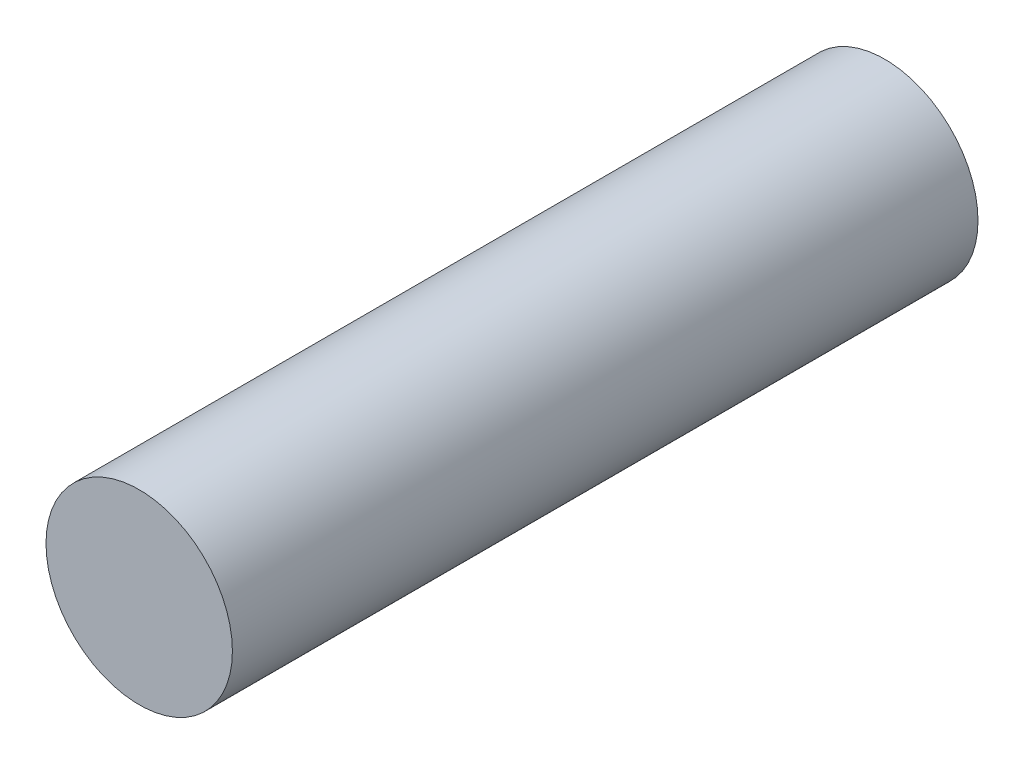
from build123d import *

# Parameters (mm, degrees)
SKETCH1_R           = 4.7625
BOSS_EXTRUDE1_DEPTH = 38.1


with BuildPart() as part:
    # Sketch1 → Boss-Extrude1 (new body)
    with BuildSketch(Plane.XY):
        Circle(SKETCH1_R)
    extrude(amount=BOSS_EXTRUDE1_DEPTH)


solid = part.part
